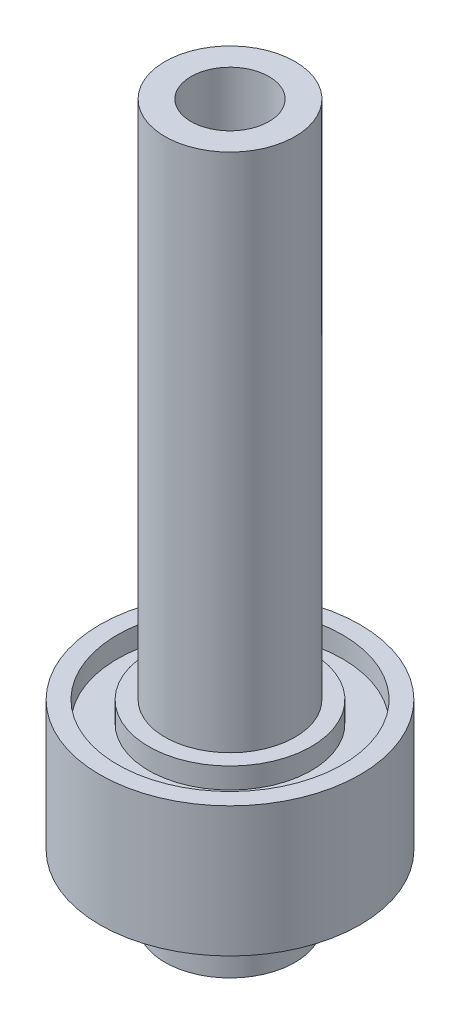
from build123d import *


with BuildPart() as part:
    # Sketch1 → Revolve1 (revolve)
    with BuildSketch(Plane.XY):
        Polygon((-3.81, 0), (-6.35, 0), (-6.35, 6.35), (-7.9375, 6.35), (-7.9375, 8.382), (-10.9855, 8.382), (-10.9855, 6.35), (-12.7, 6.35), (-12.7, 19.05), (-10.9855, 19.05), (-10.9855, 17.018), (-7.9375, 17.018), (-7.9375, 19.05), (-6.35, 19.05), (-6.35, 69.85), (-3.81, 69.85), align=None)
    revolve(axis=Axis((0, 0, 0), (0, 1, 0)))


solid = part.part
